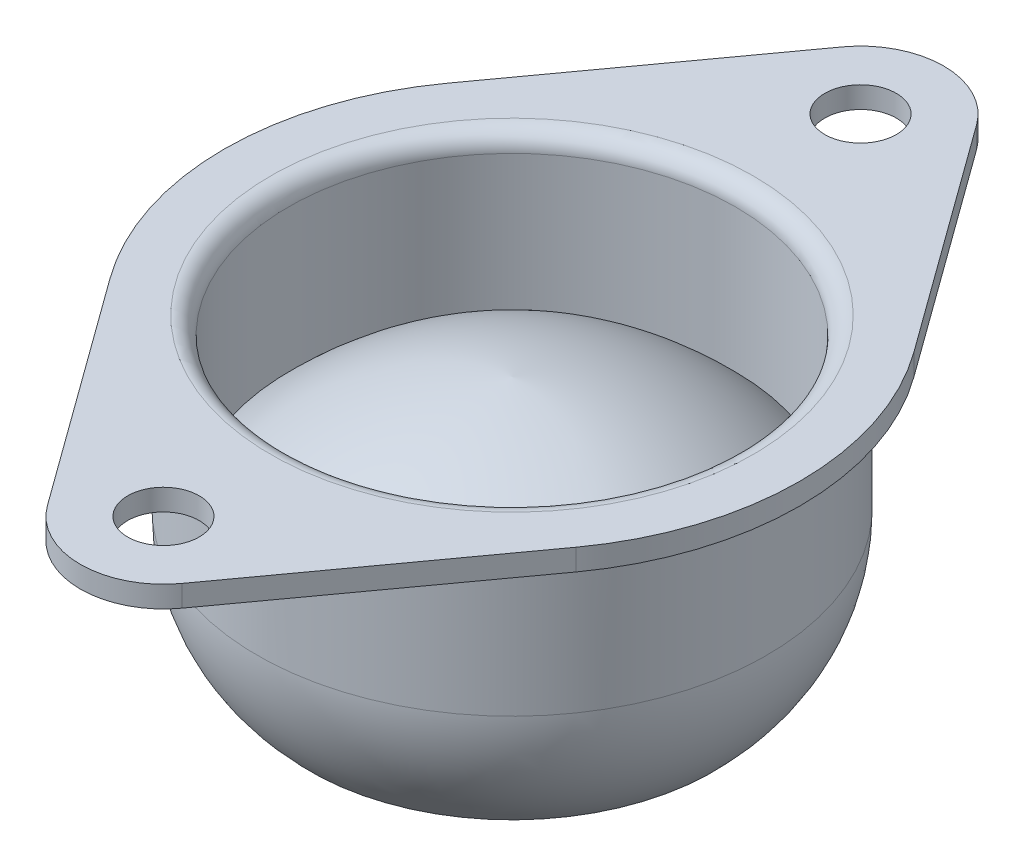
from build123d import *

# Parameters (mm, degrees)
ESBO_O2_R                = 2
RESSALTO_EXTRUS_O1_DEPTH = 1.2
FILETE1_R                = 1
FILETE2_R                = 1
ESCALA1_SCALE            = 0.571428571


with BuildPart() as part:
    # Esboço1 → Revolução1 (revolve)
    with BuildSketch(Plane.XY):
        with BuildLine():
            Line((0, 0), (-16.1, 0))
            Line((-16.1, 0), (-16.1, -1.2))
            Line((-16.1, -1.2), (-14.25, -1.2))
            Line((-14.25, -1.2), (-14.25, -9.358571571))
            ThreePointArc((-14.25, -9.358571571), (-13.469544457, -13.231554918), (-11.25, -16.5))
            ThreePointArc((-11.25, -16.5), (-9.286251005, -16.915617464), (-7.5, -16))
            ThreePointArc((-7.5, -16), (-4.506939094, -19.635408641), (0, -21))
            Line((0, -21), (0, 0))
        make_face()
    revolve(axis=Axis((0, 0, 0), (0, 1, 0)))

    # Esboço2 → Ressalto-extrusão1 (add)
    with BuildSketch(Plane(origin=(0, 0, 0), x_dir=(1, 0, 0), z_dir=(0, 1, 0))):
        with BuildLine():
            Line((13.032253871, 9.453589744), (3.763973944, 22.230384615))
            ThreePointArc((3.763973944, 22.230384615), (0, 24.15), (-3.763973944, 22.230384615))
            Line((-3.763973944, 22.230384615), (-13.032253871, 9.453589744))
            ThreePointArc((-13.032253871, 9.453589744), (0, 16.1), (13.032253871, 9.453589744))
        make_face()
        with Locations((0, 19.5)):
            Circle(ESBO_O2_R, mode=Mode.SUBTRACT)
        with BuildLine():
            Line((3.763973944, -22.230384615), (13.032253871, -9.453589744))
            ThreePointArc((13.032253871, -9.453589744), (0, -16.1), (-13.032253871, -9.453589744))
            Line((-13.032253871, -9.453589744), (-3.763973944, -22.230384615))
            ThreePointArc((-3.763973944, -22.230384615), (0, -24.15), (3.763973944, -22.230384615))
        make_face()
        with Locations((0, -19.5)):
            Circle(ESBO_O2_R, mode=Mode.SUBTRACT)
    extrude(amount=-RESSALTO_EXTRUS_O1_DEPTH)

    # Esboço3 → Corte-Revolução1 (revolve, cut)
    with BuildSketch(Plane(origin=(0, 0, 0), x_dir=(0, 0, -1), z_dir=(1, 0, 0))):
        with BuildLine():
            Line((-12.5, 0), (-12.5, -9))
            ThreePointArc((-12.5, -9), (-6.786587677, -4.882109006), (0, -3))
            Line((0, -3), (0, 0))
            Line((0, 0), (-12.5, 0))
        make_face()
    revolve(axis=Axis((0, 0, 0), (0, -1, 0)), mode=Mode.SUBTRACT)

    # Filete1
    filete1_edges = [part.edges().sort_by_distance(p)[0] for p in [
        (0, 0, -12.5),
    ]]
    fillet(filete1_edges, radius=FILETE1_R)

    # Filete2
    filete2_edges = [part.edges().sort_by_distance(p)[0] for p in [
        (14.25, -1.2, 0),
    ]]
    fillet(filete2_edges, radius=FILETE2_R)


with BuildPart() as part_1:
    # Escala1: scaled about (0, -9.829669645, 0)
    add(part.part.scale(ESCALA1_SCALE).moved(Location((0, -4.212715562, 0))))


solid = part_1.part
